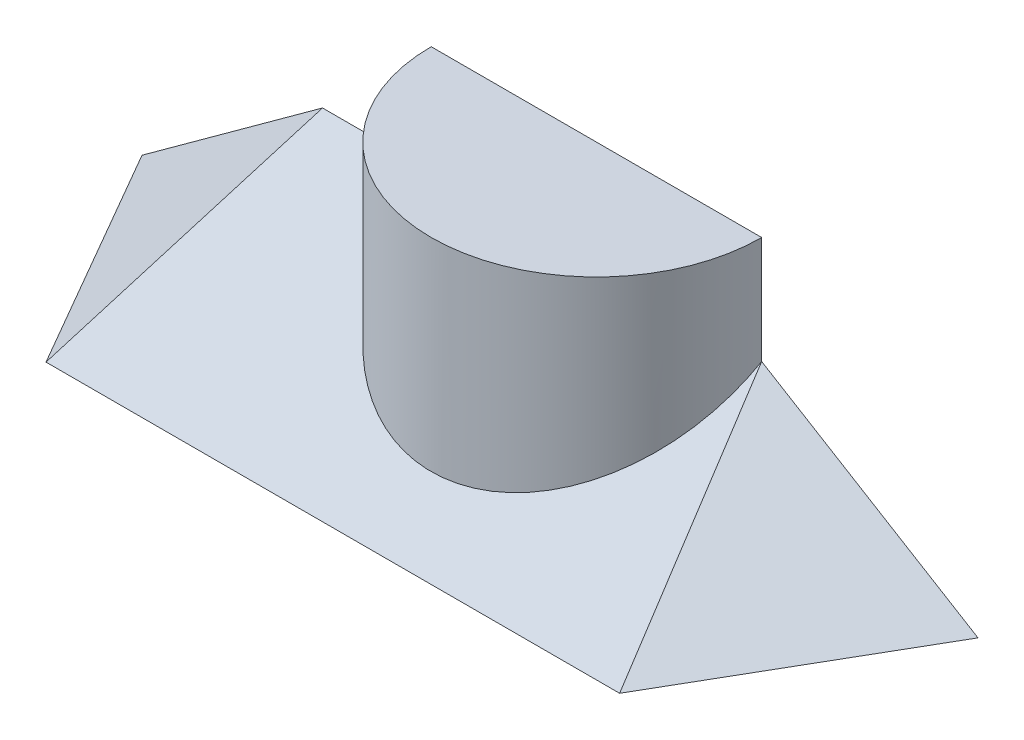
from build123d import *

# Parameters (mm, degrees)
EXTRUDE1_DEPTH      = 40
EXTRUDE1_DEPTH_BACK = 78.25
EXTRUDE2_DEPTH      = 31.755
EXTRUDE4_DEPTH      = 51.755
SKETCH7_W           = 50.762718211
SKETCH7_H           = 77.693391575
CUT_EXTRUDE1_DEPTH  = 10
SKETCH8_W           = 180.54307219
SKETCH8_H           = 130.318791492
CUT_EXTRUDE2_DEPTH  = 40
SKETCH9_W           = 213.468812953
SKETCH9_H           = 29.374372581
CUT_EXTRUDE3_DEPTH  = 32.754264805
EXTRUDE5_DEPTH      = 57.75


with BuildPart() as part:
    # Sketch2 → Extrude1 (new body, two sides)
    with BuildSketch(Plane(origin=(0, 0, 0), x_dir=(0, 0, -1), z_dir=(1, 0, 0))) as extrude1_sk:
        Polygon((0, 0), (0, 31.754264805), (-55, 0), align=None)
    extrude(amount=EXTRUDE1_DEPTH)
    extrude(extrude1_sk.sketch, amount=-EXTRUDE1_DEPTH_BACK)

    # Sketch4 → Extrude2 (add, symmetric)
    with BuildSketch(Plane(origin=(-11.6225, 0, -20.130760511), x_dir=(0.866025404, 0, -0.5), z_dir=(0.5, 0, 0.866025404))):
        Polygon((-95.266487846, 0), (-57.423228684, 31.754264805), (-57.423228684, 0), align=None)
    extrude(amount=EXTRUDE2_DEPTH, both=True)

    # Sketch6 → Extrude4 (add, symmetric)
    with BuildSketch(Plane(origin=(-1.270622992, 0, 2.200783579), x_dir=(0.866025404, 0, 0.5), z_dir=(-0.5, 0, 0.866025404))):
        Polygon((34.641016151, 31.754264805), (79.990806139, 0), (34.641016151, 0), align=None)
    extrude(amount=EXTRUDE4_DEPTH, both=True)

    # Sketch7 → Cut-Extrude1 (cut)
    with BuildSketch(Plane(origin=(-34.088334257, 46.909587917, 19.68090896), x_dir=(-0.830733451, -0.513322613, -0.215364408), z_dir=(-0.556670399, 0.766044443, 0.321393805))):
        with Locations((42.354713251, 21.026293217)):
            Rectangle(SKETCH7_W, SKETCH7_H)
    extrude(amount=CUT_EXTRUDE1_DEPTH, mode=Mode.SUBTRACT)

    # Sketch8 → Cut-Extrude2 (cut)
    with BuildSketch(Plane(origin=(0, 23.815698604, 13.75), x_dir=(-1, 0, 0), z_dir=(0, 0.866025404, 0.5))):
        with Locations((7.268110747, 13.895626923)):
            Rectangle(SKETCH8_W, SKETCH8_H)
    extrude(amount=CUT_EXTRUDE2_DEPTH, mode=Mode.SUBTRACT)

    # Sketch9 → Cut-Extrude3 (cut, through all)
    with BuildSketch(Plane(origin=(0, 0, 0), x_dir=(1, 0, 0), z_dir=(0, 1, 0))):
        with Locations((-3.268792127, 14.685339576)):
            Rectangle(SKETCH9_W, SKETCH9_H)
    extrude(amount=CUT_EXTRUDE3_DEPTH, mode=Mode.SUBTRACT)

    # Sketch1 → Extrude5 (add)
    with BuildSketch(Plane(origin=(0, 0, 0), x_dir=(1, 0, 0), z_dir=(0, 1, 0))):
        with BuildLine():
            Line((40, 0), (-40, 0))
            ThreePointArc((-40, 0), (0, -40), (40, 0))
        make_face()
    extrude(amount=EXTRUDE5_DEPTH)


solid = part.part
